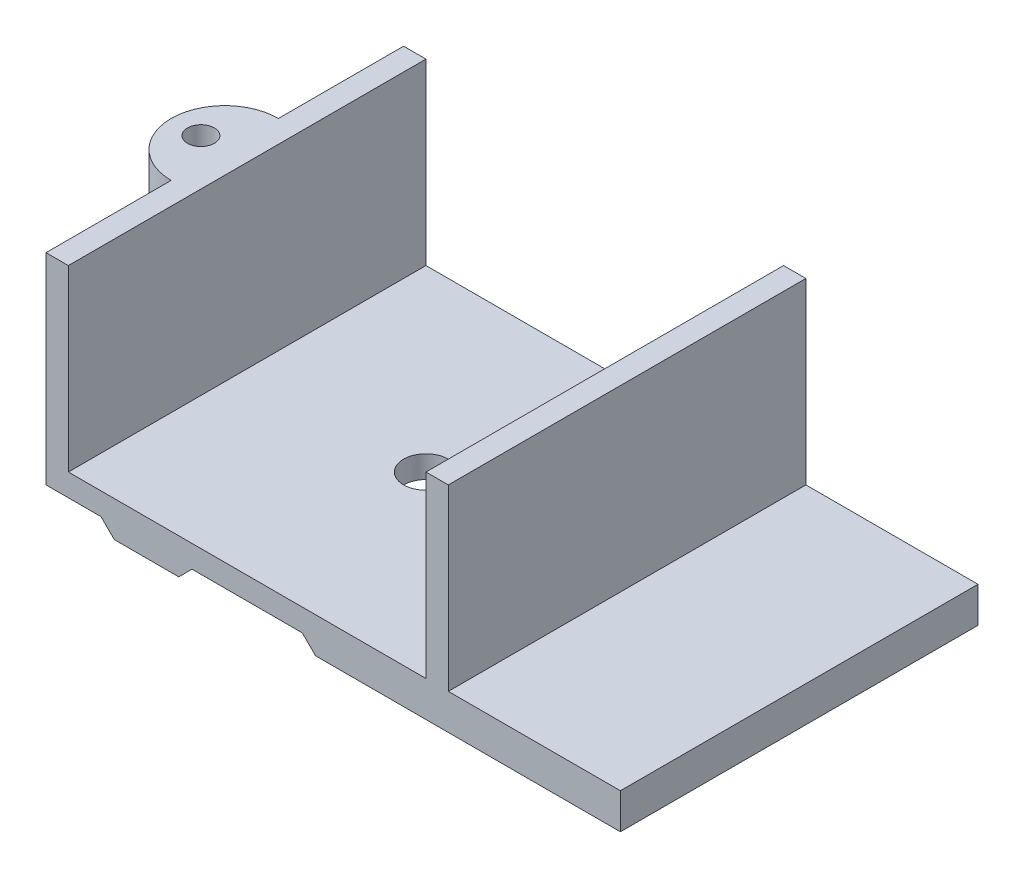
from build123d import *

# Parameters (mm, degrees)
BOSS_EXTRUDE2_DEPTH             = 80
SKETCH2_R                       = 3
BOSS_EXTRUDE3_DEPTH             = 45
SKETCH3_R                       = 5
CUT_EXTRUDE1_DEPTH              = 8.959911114
BOSS_EXTRUDE4_DEPTH             = 38.5
BOSS_EXTRUDE4_DIRECTION_2_REACH = 104


with BuildPart() as part:
    # Sketch1 → Boss-Extrude2 (new body)
    with BuildSketch(Plane.XY):
        Polygon((9.382877742, 0), (0, 0), (0, 40), (-5, 40), (-5, -5), (7.31180993, -5), (10.271721045, -7.959911114), (24.701165041, -7.959911114), (27.661076156, -5), (52.338923844, -5), (55.298834959, -7.959911114), (69.728278955, -7.959911114), (72.68819007, -5), (85, -5), (85, 40), (80, 40), (80, 0), (70.617122258, 0), (54.409991656, 0), (25.590008344, 0), align=None)
    extrude(amount=BOSS_EXTRUDE2_DEPTH)

    # Sketch2 → Boss-Extrude3 (add)
    with BuildSketch(Plane(origin=(0, 40, 0), x_dir=(1, 0, 0), z_dir=(0, 1, 0))):
        with BuildLine():
            Line((-5, -28), (-5, -52))
            ThreePointArc((-5, -52), (-17, -40), (-5, -28))
        make_face()
        with Locations((-10.338111961, -40)):
            Circle(SKETCH2_R, mode=Mode.SUBTRACT)
    extrude(amount=-BOSS_EXTRUDE3_DEPTH)

    # Sketch3 → Cut-Extrude1 (cut, through all)
    with BuildSketch(Plane(origin=(0, 0, 0), x_dir=(1, 0, 0), z_dir=(0, 1, 0))):
        with Locations((40, -40)):
            Circle(SKETCH3_R)
    extrude(amount=-CUT_EXTRUDE1_DEPTH, mode=Mode.SUBTRACT)

    # Sketch5 → Boss-Extrude4 (add)
    with BuildSketch(Plane(origin=(85, 0, 0), x_dir=(0, 0, -1), z_dir=(1, 0, 0))):
        Polygon((-80, -5), (-80, -7.959911114), (0, -7.959911114), (0, -5), (0, 0), (-80, 0), align=None)
    extrude(amount=BOSS_EXTRUDE4_DEPTH)

    # Boss-Extrude4 direction 2: up to this face of the body (flat: up to its plane)
    boss_extrude4_direction_2_end = Plane(part.part.faces().sort_by_distance((71.208234512, -6.479955557, 40))[0])
    # Sketch5 → Boss-Extrude4 direction 2 (add, up to the picked face)
    with BuildSketch(Plane(origin=(85, 0, 0), x_dir=(0, 0, -1), z_dir=(1, 0, 0)), mode=Mode.PRIVATE) as boss_extrude4_direction_2_sk1:
        Polygon((-80, -5), (-80, -7.959911114), (0, -7.959911114), (0, -5), (0, 0), (-80, 0), align=None)
    boss_extrude4_direction_2_tool1 = split(extrude(boss_extrude4_direction_2_sk1.sketch, amount=-BOSS_EXTRUDE4_DIRECTION_2_REACH, mode=Mode.PRIVATE), bisect_by=boss_extrude4_direction_2_end, keep=Keep.BOTH, mode=Mode.PRIVATE)
    add(boss_extrude4_direction_2_tool1.solids().sort_by_distance((85, -3.979956, 40))[0])


solid = part.part
